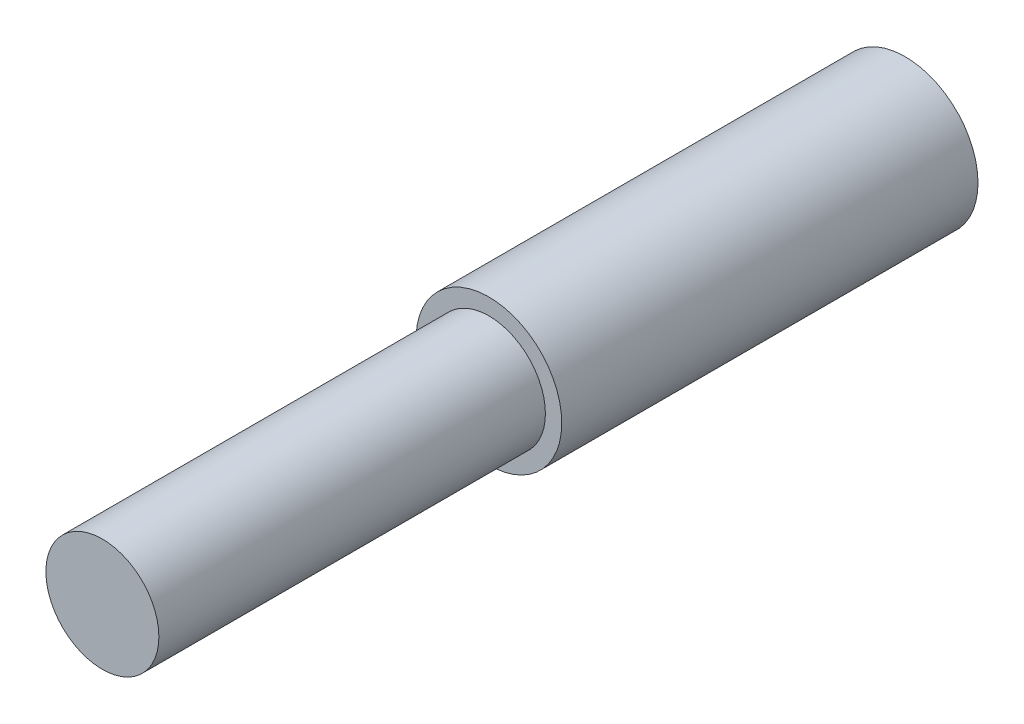
from build123d import *

# Parameters (mm, degrees)
SKETCH1_R           = 6.223
BOSS_EXTRUDE1_DEPTH = 35.56
SKETCH2_R           = 4.826
BOSS_EXTRUDE2_DEPTH = 33.02


with BuildPart() as part:
    # Sketch1 → Boss-Extrude1 (new body)
    with BuildSketch(Plane.XY):
        Circle(SKETCH1_R)
    extrude(amount=BOSS_EXTRUDE1_DEPTH)

    # Sketch2 → Boss-Extrude2 (add)
    with BuildSketch(Plane.XY.offset(35.56)):
        Circle(SKETCH2_R)
    extrude(amount=BOSS_EXTRUDE2_DEPTH)


solid = part.part
